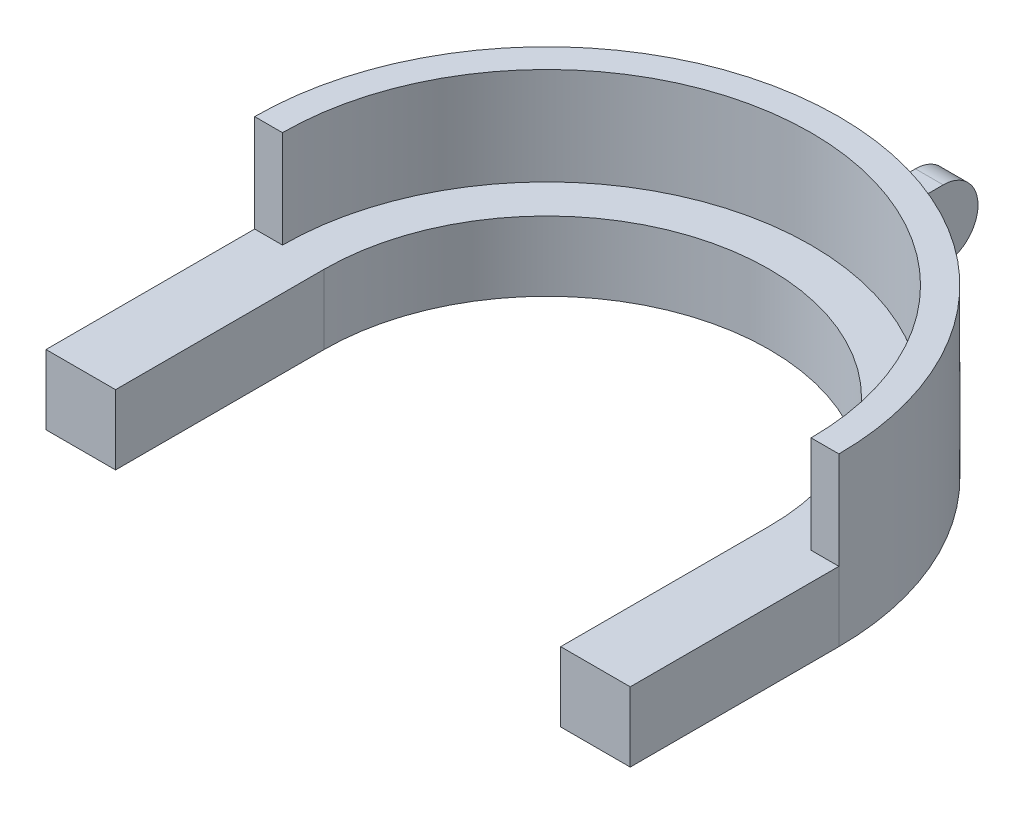
from build123d import *

# Parameters (mm, degrees)
EXTRUDE_1_DEPTH     = 10
EXTRUDE_2_DEPTH     = 24
SKETCH_3_W          = 4
SKETCH_3_H          = 24
SKETCH_3_W_2        = 10
SKETCH_3_H_2        = 30
EXTRUDE_3_DEPTH     = 10
CUT_EXTRUDE_1_DEPTH = 10


with BuildPart() as part:
    # 草图1 → 凸台-拉伸1 (new body)
    with BuildSketch(Plane(origin=(0, 0, 0), x_dir=(1, 0, 0), z_dir=(0, 1, 0))):
        with BuildLine():
            Line((-38, 0), (-32, 0))
            ThreePointArc((-32, 0), (0, 32), (32, 0))
            Line((32, 0), (38, 0))
            ThreePointArc((38, 0), (0, 38), (-38, 0))
        make_face()
    extrude(amount=EXTRUDE_1_DEPTH)

    # 草图2 → 凸台-拉伸2 (add)
    with BuildSketch(Plane.XZ):
        with BuildLine():
            Line((-38, 0), (-42, 0))
            ThreePointArc((-42, 0), (0, -42), (42, 0))
            Line((42, 0), (38, 0))
            ThreePointArc((38, 0), (0, -38), (-38, 0))
        make_face()
    extrude(amount=-EXTRUDE_2_DEPTH)

    # 草图3 → 凸台-拉伸3 (add)
    with BuildSketch(Plane.XZ):
        with Locations((0, -48)):
            Rectangle(SKETCH_3_W, SKETCH_3_H)
        with Locations((-37, 15)):
            Rectangle(SKETCH_3_W_2, SKETCH_3_H_2)
        with Locations((37, 15)):
            Rectangle(SKETCH_3_W_2, SKETCH_3_H_2)
    extrude(amount=-EXTRUDE_3_DEPTH)

    # 草图4 → 切除-拉伸1 (cut)
    with BuildSketch(Plane.ZY.offset(2)):
        with BuildLine():
            Line((-55, 10), (-63.230439801, 10))
            Line((-63.230439801, 10), (-63.230439801, 0))
            Line((-63.230439801, 0), (-55, 0))
            ThreePointArc((-55, 0), (-60, 5), (-55, 10))
        make_face()
    extrude(amount=-CUT_EXTRUDE_1_DEPTH, mode=Mode.SUBTRACT)


solid = part.part
